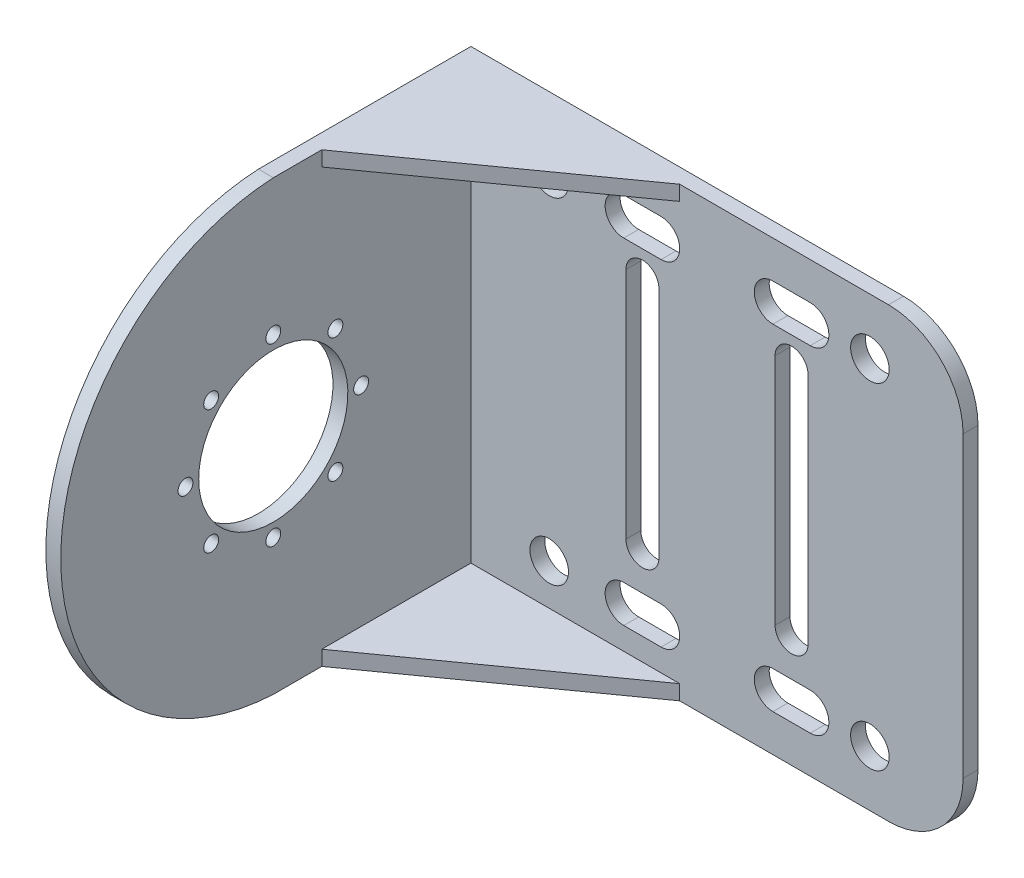
from build123d import *

# Parameters (mm, degrees)
BOSS_EXTRUDE1_DEPTH = 2
SKETCH5_W           = 2
SKETCH5_H           = 60
BOSS_EXTRUDE2_DEPTH = 55
SKETCH6_R           = 10
SKETCH6_R_2         = 1
CUT_EXTRUDE2_DEPTH  = 55
SKETCH8_R           = 2.585315043
CUT_EXTRUDE3_DEPTH  = 55
SKETCH4_W           = 30
SKETCH4_H           = 2
BOSS_EXTRUDE3_DEPTH = 20
CUT_EXTRUDE4_DEPTH  = 100


with BuildPart() as part:
    # Sketch2 → Boss-Extrude1 (new body)
    with BuildSketch(Plane.XY):
        with BuildLine():
            Line((-34, -30), (24, -30))
            ThreePointArc((24, -30), (31.071067812, -27.071067812), (34, -20))
            Line((34, -20), (34, 20))
            ThreePointArc((34, 20), (31.071067812, 27.071067812), (24, 30))
            Line((24, 30), (-34, 30))
            Line((-34, 30), (-34, -30))
        make_face()
    extrude(amount=BOSS_EXTRUDE1_DEPTH)

    # Sketch5 → Boss-Extrude2 (add)
    with BuildSketch(Plane.XY.offset(2)):
        with Locations((-33, 0)):
            Rectangle(SKETCH5_W, SKETCH5_H)
    extrude(amount=BOSS_EXTRUDE2_DEPTH)

    # Sketch6 → Cut-Extrude2 (cut)
    with BuildSketch(Plane.ZY.offset(34)):
        with Locations((28.5, 0)):
            Circle(SKETCH6_R)
        with Locations((40.277915604, 0)):
            Circle(SKETCH6_R_2)
        with Locations((36.828243992, -8.328243992)):
            Circle(SKETCH6_R_2)
        with Locations((28.5, -11.777915604)):
            Circle(SKETCH6_R_2)
        with Locations((20.171756008, -8.328243992)):
            Circle(SKETCH6_R_2)
        with Locations((16.722084396, 0)):
            Circle(SKETCH6_R_2)
        with Locations((20.171756008, 8.328243992)):
            Circle(SKETCH6_R_2)
        with Locations((28.5, 11.777915604)):
            Circle(SKETCH6_R_2)
        with Locations((36.828243992, 8.328243992)):
            Circle(SKETCH6_R_2)
        with BuildLine():
            Line((57, 30), (28.5, 30))
            ThreePointArc((28.5, 30), (48.739127681, 20.68967138), (57, 1.21e-07))
            Line((57, 1.21e-07), (57, 30))
        make_face()
        with BuildLine():
            Line((57, -30), (57, 1.21e-07))
            ThreePointArc((57, 1.21e-07), (48.739127764, -20.689671292), (28.5, -30))
            Line((28.5, -30), (57, -30))
        make_face()
    extrude(amount=-CUT_EXTRUDE2_DEPTH, mode=Mode.SUBTRACT)

    # Sketch8 → Cut-Extrude3 (cut)
    with BuildSketch(Plane.XY.offset(2)):
        with Locations((-21.5, 22.5)):
            Circle(SKETCH8_R)
        with BuildLine():
            Line((-11.5, 20), (-6.5, 20))
            ThreePointArc((-6.5, 20), (-4, 22.5), (-6.5, 25))
            Line((-6.5, 25), (-11.5, 25))
            ThreePointArc((-11.5, 25), (-14, 22.5), (-11.5, 20))
        make_face()
        with BuildLine():
            Line((8.5, 20), (13.5, 20))
            ThreePointArc((13.5, 20), (16, 22.5), (13.5, 25))
            Line((13.5, 25), (8.5, 25))
            ThreePointArc((8.5, 25), (6, 22.5), (8.5, 20))
        make_face()
        with Locations((21.5, 22.5)):
            Circle(SKETCH8_R)
        with BuildLine():
            Line((8.786451989, 16.481383401), (8.786451989, -14.819395159))
            ThreePointArc((8.786451989, -14.819395159), (11, -17.03294317), (13.213548011, -14.819395159))
            Line((13.213548011, -14.819395159), (13.213548011, 16.481383401))
            ThreePointArc((13.213548011, 16.481383401), (11, 18.694931413), (8.786451989, 16.481383401))
        make_face()
        with BuildLine():
            Line((-11.213548011, 16.481383401), (-11.213548011, -14.819395159))
            ThreePointArc((-11.213548011, -14.819395159), (-9, -17.03294317), (-6.786451989, -14.819395159))
            Line((-6.786451989, -14.819395159), (-6.786451989, 16.481383401))
            ThreePointArc((-6.786451989, 16.481383401), (-9, 18.694931413), (-11.213548011, 16.481383401))
        make_face()
        with Locations((-21.5, -22.5)):
            Circle(SKETCH8_R)
        with BuildLine():
            ThreePointArc((-6.5, -20), (-4, -22.5), (-6.5, -25))
            Line((-6.5, -25), (-11.5, -25))
            ThreePointArc((-11.5, -25), (-14, -22.5), (-11.5, -20))
            Line((-11.5, -20), (-6.5, -20))
        make_face()
        with BuildLine():
            ThreePointArc((13.5, -20), (16, -22.5), (13.5, -25))
            Line((13.5, -25), (8.5, -25))
            ThreePointArc((8.5, -25), (6, -22.5), (8.5, -20))
            Line((8.5, -20), (13.5, -20))
        make_face()
        with Locations((21.5, -22.5)):
            Circle(SKETCH8_R)
    extrude(amount=-CUT_EXTRUDE3_DEPTH, mode=Mode.SUBTRACT)

    # Sketch4 → Boss-Extrude3 (add)
    with BuildSketch(Plane.XY.offset(2)):
        with Locations((-19, -29)):
            Rectangle(SKETCH4_W, SKETCH4_H)
        with Locations((-19, 29)):
            Rectangle(SKETCH4_W, SKETCH4_H)
    extrude(amount=BOSS_EXTRUDE3_DEPTH)

    # Sketch10 → Cut-Extrude4 (cut)
    with BuildSketch(Plane.XZ.offset(30)):
        Polygon((-32, 22), (-4, 2), (-4, 22), align=None)
    extrude(amount=-CUT_EXTRUDE4_DEPTH, mode=Mode.SUBTRACT)


solid = part.part
